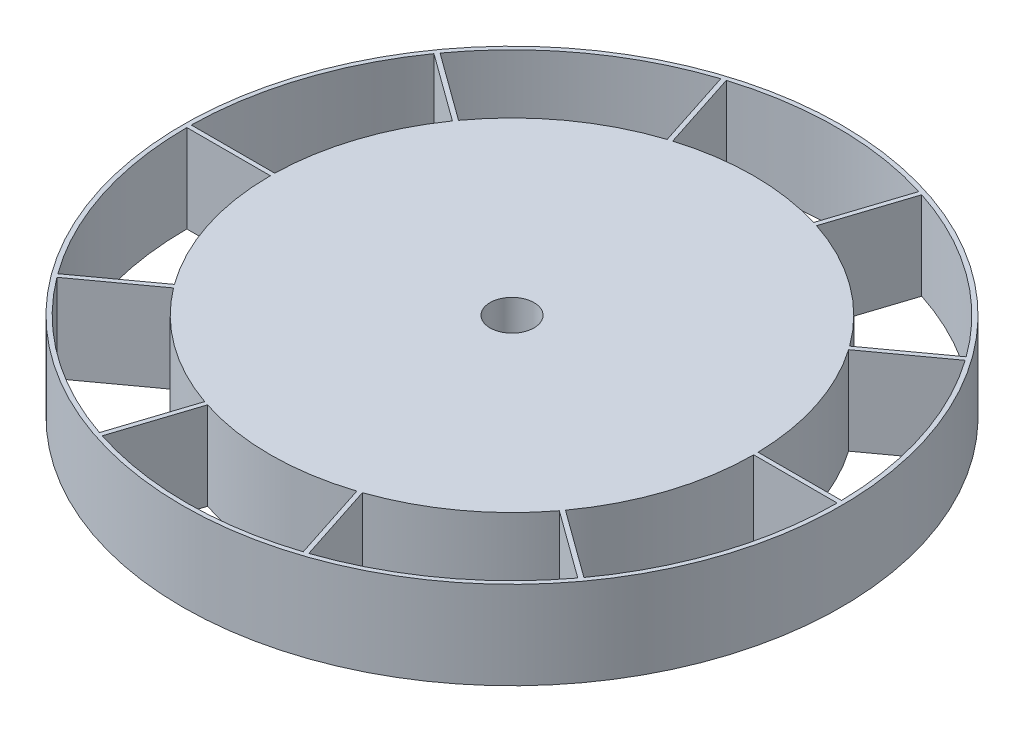
from build123d import *

# Parameters (mm, degrees)
SKETCH1_R           = 75
SKETCH1_R_2         = 74
BOSS_EXTRUDE1_DEPTH = 20
SKETCH2_R           = 55
BOSS_EXTRUDE2_DEPTH = 20
BOSS_EXTRUDE3_DEPTH = 20
SKETCH4_R           = 52
CUT_EXTRUDE3_DEPTH  = 10
SKETCH5_R           = 5
CUT_EXTRUDE4_DEPTH  = 21


with BuildPart() as part:
    # Sketch1 → Boss-Extrude1 (new body)
    with BuildSketch(Plane(origin=(0, 0, 0), x_dir=(1, 0, 0), z_dir=(0, 1, 0))):
        Circle(SKETCH1_R)
        Circle(SKETCH1_R_2, mode=Mode.SUBTRACT)
    extrude(amount=BOSS_EXTRUDE1_DEPTH)



with BuildPart() as body_2:
    # Sketch2 → Boss-Extrude2 (new body)
    with BuildSketch(Plane(origin=(0, 0, 0), x_dir=(1, 0, 0), z_dir=(0, 1, 0))):
        Circle(SKETCH2_R)
    extrude(amount=BOSS_EXTRUDE2_DEPTH)


with BuildPart() as part_1:
    add(part.part)

    add(body_2.part)  # Boss-Extrude3 merges body 2
    # Sketch3 → Boss-Extrude3 (add)
    with BuildSketch(Plane(origin=(0, 0, 0), x_dir=(1, 0, 0), z_dir=(0, 1, 0))):
        with BuildLine():
            Line((-74, 0), (-1.701301617, 0))
            Line((-1.701301617, 0), (-1.175570505, -0.381966011))
            Line((-1.175570505, -0.381966011), (-1.37638192, -1))
            Line((-1.37638192, -1), (-59.867257584, -43.49610867))
            ThreePointArc((-59.867257584, -43.49610867), (-59.571991588, -43.899633464), (-59.274005751, -44.301153961))
            Line((-59.274005751, -44.301153961), (-1.902113033, -2.618033989))
            Line((-1.902113033, -2.618033989), (-23.816226052, -70.062738861))
            ThreePointArc((-23.816226052, -70.062738861), (-23.34227468, -70.222063575), (-22.867257584, -70.378182206))
            Line((-22.867257584, -70.378182206), (-0.525731112, -1.618033989))
            Line((-0.525731112, -1.618033989), (0, -1.236067977))
            Line((0, -1.236067977), (0.525731112, -1.618033989))
            Line((0.525731112, -1.618033989), (22.867257584, -70.378182206))
            ThreePointArc((22.867257584, -70.378182206), (23.34227468, -70.222063575), (23.816226052, -70.062738861))
            Line((23.816226052, -70.062738861), (1.902113033, -2.618033989))
            Line((1.902113033, -2.618033989), (59.274005751, -44.301153961))
            ThreePointArc((59.274005751, -44.301153961), (59.571991588, -43.899633464), (59.867257584, -43.49610867))
            Line((59.867257584, -43.49610867), (1.37638192, -1))
            Line((1.37638192, -1), (1.175570505, -0.381966011))
            Line((1.175570505, -0.381966011), (1.701301617, 0))
            Line((1.701301617, 0), (74, 0))
            ThreePointArc((74, 0), (73.998310714, 0.500011414), (73.993242935, 1))
            Line((73.993242935, 1), (3.077683537, 1))
            Line((3.077683537, 1), (60.449576255, 42.683119972))
            ThreePointArc((60.449576255, 42.683119972), (60.159790258, 43.090598001), (59.867257584, 43.49610867))
            Line((59.867257584, 43.49610867), (1.37638192, 1))
            Line((1.37638192, 1), (0.726542528, 1))
            Line((0.726542528, 1), (0.525731112, 1.618033989))
            Line((0.525731112, 1.618033989), (22.867257584, 70.378182206))
            ThreePointArc((22.867257584, 70.378182206), (22.391196452, 70.531087624), (21.914113019, 70.680772849))
            Line((21.914113019, 70.680772849), (0, 3.236067977))
            Line((0, 3.236067977), (-21.914113019, 70.680772849))
            ThreePointArc((-21.914113019, 70.680772849), (-22.391196452, 70.531087624), (-22.867257584, 70.378182206))
            Line((-22.867257584, 70.378182206), (-0.525731112, 1.618033989))
            Line((-0.525731112, 1.618033989), (-0.726542528, 1))
            Line((-0.726542528, 1), (-1.37638192, 1))
            Line((-1.37638192, 1), (-59.867257584, 43.49610867))
            ThreePointArc((-59.867257584, 43.49610867), (-60.159790258, 43.090598001), (-60.449576255, 42.683119972))
            Line((-60.449576255, 42.683119972), (-3.077683537, 1))
            Line((-3.077683537, 1), (-73.993242935, 1))
            ThreePointArc((-73.993242935, 1), (-73.998310714, 0.500011414), (-74, 0))
        make_face()
    extrude(amount=BOSS_EXTRUDE3_DEPTH)

    # Sketch4 → Cut-Extrude3 (cut)
    with BuildSketch(Plane(origin=(0, 0, 0), x_dir=(1, 0, 0), z_dir=(0, 1, 0))):
        Circle(SKETCH4_R)
    extrude(amount=CUT_EXTRUDE3_DEPTH, mode=Mode.SUBTRACT)

    # Sketch5 → Cut-Extrude4 (cut, through all)
    with BuildSketch(Plane(origin=(0, 0, 0), x_dir=(1, 0, 0), z_dir=(0, 1, 0))):
        Circle(SKETCH5_R)
    extrude(amount=CUT_EXTRUDE4_DEPTH, mode=Mode.SUBTRACT)


solid = part_1.part
